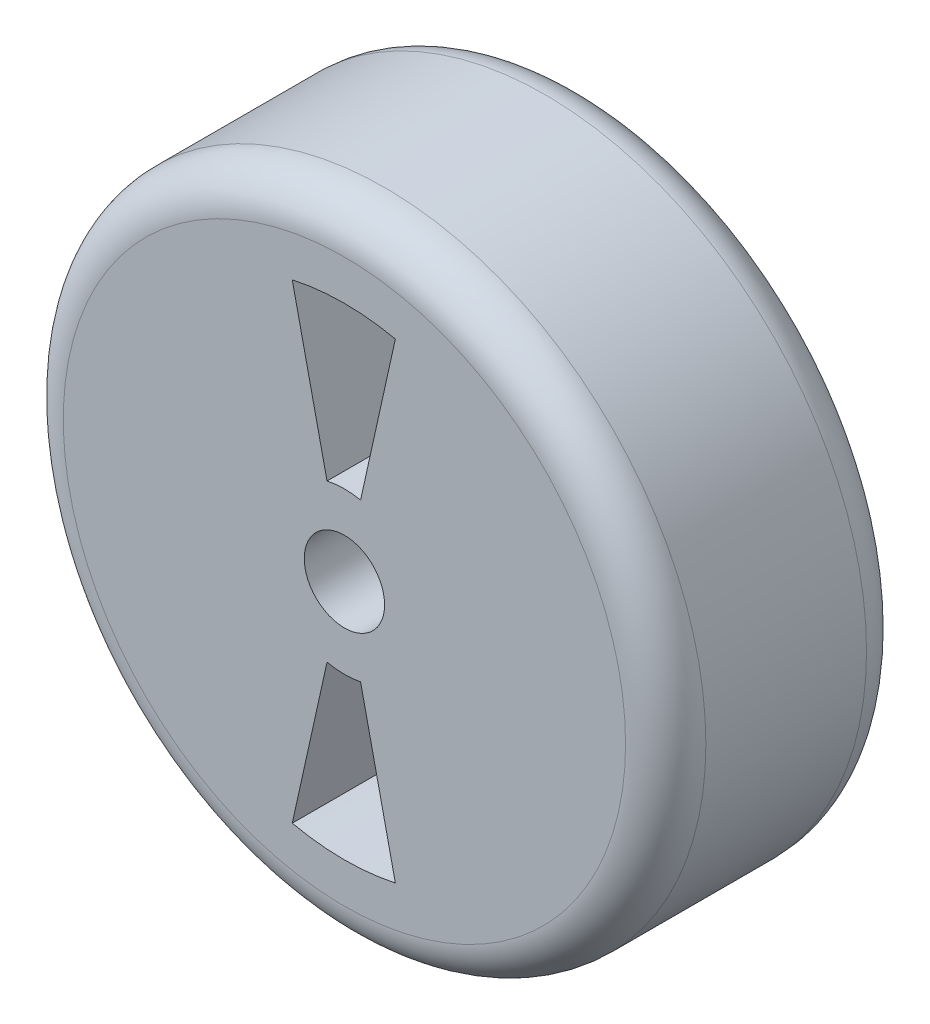
from build123d import *

# Parameters (mm, degrees)
BOSS_EXTRUDE1_DEPTH      = 38.1
BOSS_EXTRUDE1_DEPTH_BACK = 38.1
SKETCH1_R                = 101.6
SKETCH2_R                = 12.7
CUT_EXTRUDE1_DEPTH       = 163.639355631
FILLET1_R                = 12.7
FILLET2_R                = 12.7
CUT_EXTRUDE2_DEPTH       = 163.639355693


with BuildPart() as part:
    # Sketch1 → Boss-Extrude1 (new, two sides: drawn at the far end of the back side and taken through both)
    with BuildSketch(Plane.XY.offset(-BOSS_EXTRUDE1_DEPTH_BACK)):
        Circle(SKETCH1_R)
    extrude(amount=BOSS_EXTRUDE1_DEPTH + BOSS_EXTRUDE1_DEPTH_BACK)

    # Sketch2 → Cut-Extrude1 (cut, through all)
    with BuildSketch(Plane.XY.offset(38.1)):
        Circle(SKETCH2_R)
    extrude(amount=-CUT_EXTRUDE1_DEPTH, mode=Mode.SUBTRACT)

    # Fillet1
    fillet1_edges = [part.edges().sort_by_distance(p)[0] for p in [
        (-101.6, 0, 38.1),
    ]]
    fillet(fillet1_edges, radius=FILLET1_R)

    # Fillet2
    fillet2_edges = [part.edges().sort_by_distance(p)[0] for p in [
        (-101.6, 0, -38.1),
    ]]
    fillet(fillet2_edges, radius=FILLET2_R)

    # Sketch3 → Cut-Extrude2 (cut, through all)
    with BuildSketch(Plane.XY.offset(38.1)):
        with BuildLine():
            Line((5.110599479, 24.880550094), (16.107968661, 74.486476782))
            ThreePointArc((16.107968661, 74.486476782), (-0.197840063, 76.208022787), (-16.494490613, 74.401839071))
            Line((-16.494490613, 74.401839071), (-5.497566194, 24.797918581))
            ThreePointArc((-5.497566194, 24.797918581), (-0.197845398, 25.399229461), (5.110599479, 24.880550094))
        make_face()
    cut_extrude2 = extrude(amount=-CUT_EXTRUDE2_DEPTH, mode=Mode.SUBTRACT)

    # Mirror1: Cut-Extrude2 across plane
    add(cut_extrude2.mirror(Plane.ZX), mode=Mode.SUBTRACT)


solid = part.part
